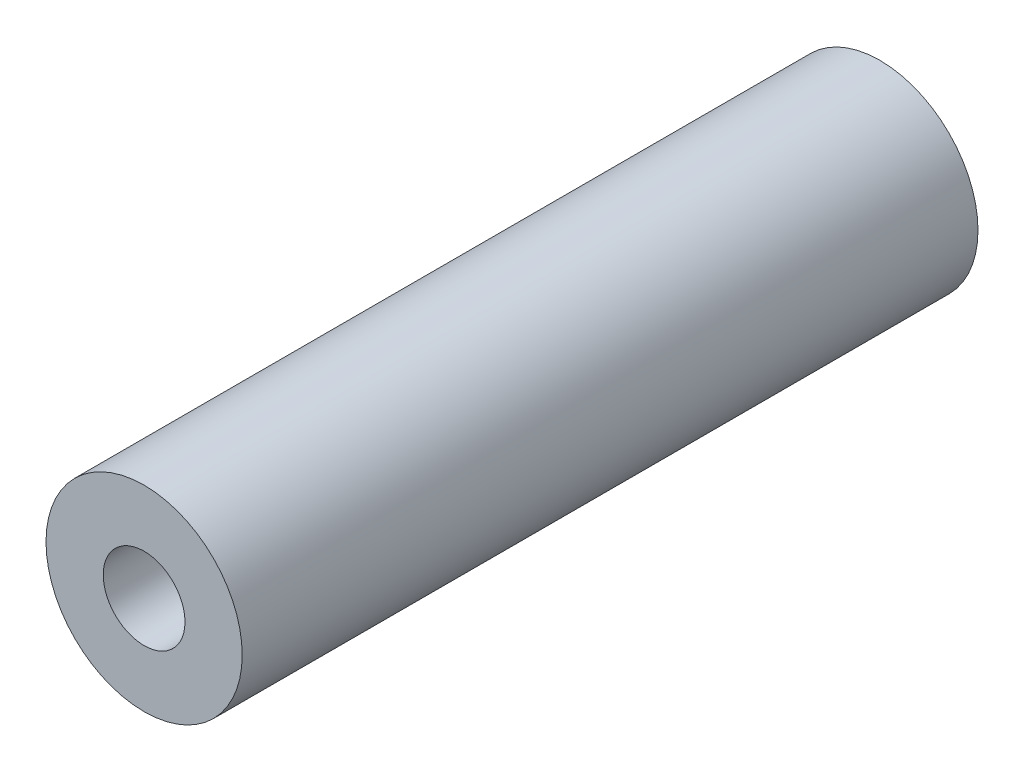
from build123d import *

# Parameters (mm, degrees)
SKETCH1_R           = 6
BOSS_EXTRUDE1_DEPTH = 45
SKETCH2_R           = 2.1
CUT_EXTRUDE1_DEPTH  = 46
SKETCH5_R           = 2.5
CUT_EXTRUDE2_DEPTH  = 22.5


with BuildPart() as part:
    # Sketch1 → Boss-Extrude1 (new body)
    with BuildSketch(Plane.XY):
        Circle(SKETCH1_R)
    extrude(amount=BOSS_EXTRUDE1_DEPTH)

    # Sketch2 → Cut-Extrude1 (cut, through all)
    with BuildSketch(Plane.XY.offset(45)):
        Circle(SKETCH2_R)
    extrude(amount=-CUT_EXTRUDE1_DEPTH, mode=Mode.SUBTRACT)

    # Sketch5 → Cut-Extrude2 (cut, symmetric)
    with BuildSketch(Plane.XY.offset(45)):
        Circle(SKETCH5_R)
    extrude(amount=CUT_EXTRUDE2_DEPTH, both=True, mode=Mode.SUBTRACT)


solid = part.part
